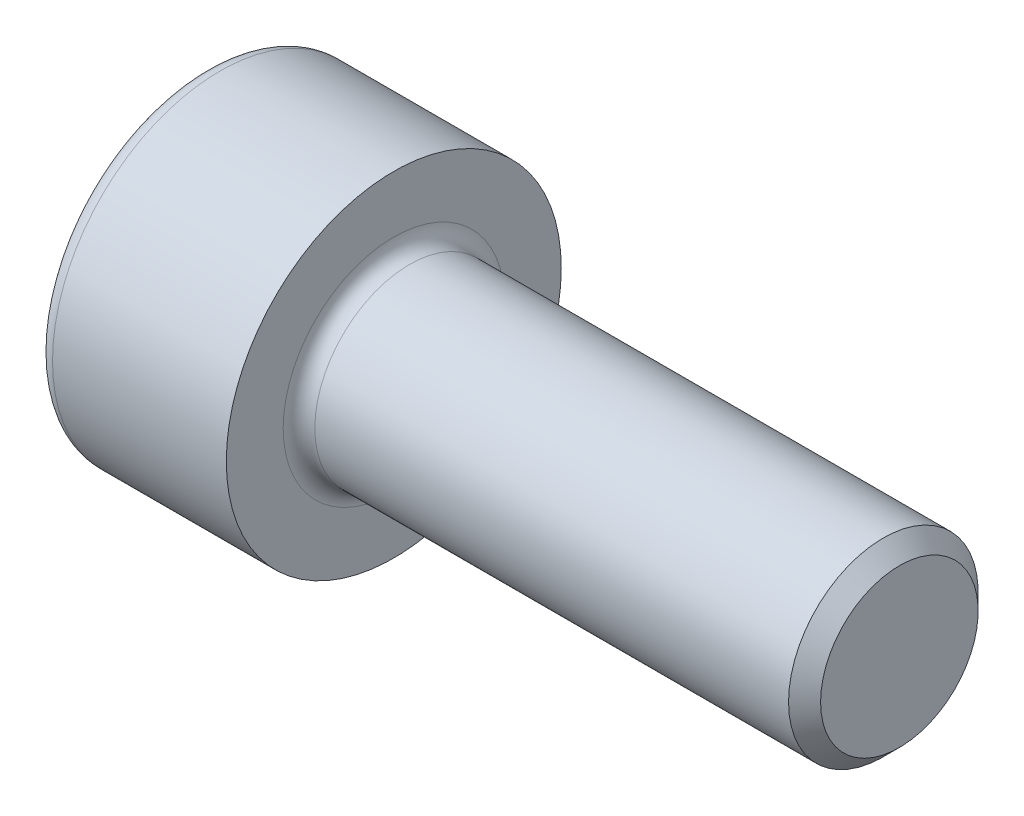
from build123d import *

# Parameters (mm, degrees)
CUT_EXTRUDE1_DEPTH = 1.1


with BuildPart() as part:
    # Sketch1 → Revolve1 (revolve)
    with BuildSketch(Plane.XY):
        with BuildLine():
            Line((7.7465, 1.5), (0.25, 1.5))
            ThreePointArc((0.25, 1.5), (0.073223305, 1.573223305), (0, 1.75))
            Line((0, 1.75), (0, 2.65))
            Line((0, 2.65), (-2.75, 2.65))
            ThreePointArc((-2.75, 2.65), (-2.926776695, 2.576776695), (-3, 2.4))
            Line((-3, 2.4), (-3, 0))
            Line((-3, 0), (8, 0))
            Line((8, 0), (8, 1.2465))
            Line((8, 1.2465), (7.7465, 1.5))
        make_face()
    revolve(axis=Axis((-3, 0, 0), (1, 0, 0)))

    # Sketch2 → Cut-Extrude1 (cut)
    with BuildSketch(Plane.ZY.offset(3)):
        Polygon((1.25, 0.721687836), (0, 1.443375673), (-1.25, 0.721687836), (-1.25, -0.721687836), (0, -1.443375673), (1.25, -0.721687836), align=None)
    extrude(amount=-CUT_EXTRUDE1_DEPTH, mode=Mode.SUBTRACT)


solid = part.part
